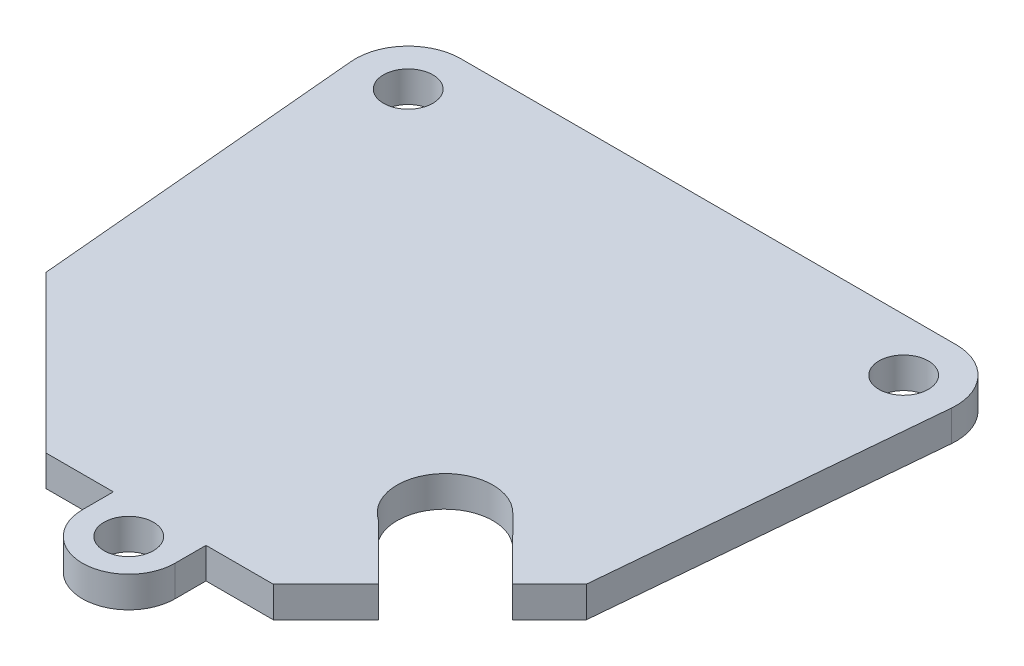
from build123d import *

# Parameters (mm, degrees)
SKETCH1_R           = 1.6
BOSS_EXTRUDE1_DEPTH = 2


with BuildPart() as part:
    # Sketch1 → Boss-Extrude1 (new body)
    with BuildSketch(Plane(origin=(0, 0, 0), x_dir=(1, 0, 0), z_dir=(0, 1, 0))):
        with BuildLine():
            ThreePointArc((7.536585866, 10.5201286), (2.958706846, 10.319962474), (3.565513998, 5.778065527))
            Line((3.565513998, 5.778065527), (7.192643667, 2.150935858))
            Line((7.192643667, 2.150935858), (3.793373086, -1.248334723))
            Line((3.793373086, -1.248334723), (-0.570702654, -1.248334723))
            Line((-0.570702654, -1.248334723), (-0.570702654, -3.253047476))
            ThreePointArc((-0.570702654, -3.253047476), (-3.570702654, -6.253047476), (-6.570702654, -3.253047476))
            Line((-6.570702654, -3.253047476), (-6.570702654, -1.248334723))
            Line((-6.570702654, -1.248334723), (-10.934778393, -1.248334723))
            Line((-10.934778393, -1.248334723), (-21.070702654, 8.887589537))
            Line((-21.070702654, 8.887589537), (-23.015874855, 30.595563989))
            ThreePointArc((-23.015874855, 30.595563989), (-22.136333563, 33.200086558), (-19.620702654, 34.308568326))
            Line((-19.620702654, 34.308568326), (12.479297346, 34.308568326))
            ThreePointArc((12.479297346, 34.308568326), (14.994928256, 33.200086558), (15.874469548, 30.595563989))
            Line((15.874469548, 30.595563989), (13.929297346, 8.887589537))
            Line((13.929297346, 8.887589537), (11.545749837, 6.504042028))
            Line((11.545749837, 6.504042028), (7.536585866, 10.5201286))
        make_face()
        with Locations((-19.620702654, 30.899792953)):
            Circle(SKETCH1_R, mode=Mode.SUBTRACT)
        with Locations((12.479297346, 30.899792953)):
            Circle(SKETCH1_R, mode=Mode.SUBTRACT)
        with Locations((-3.570702654, -3.253047476)):
            Circle(SKETCH1_R, mode=Mode.SUBTRACT)
    extrude(amount=BOSS_EXTRUDE1_DEPTH)


solid = part.part
